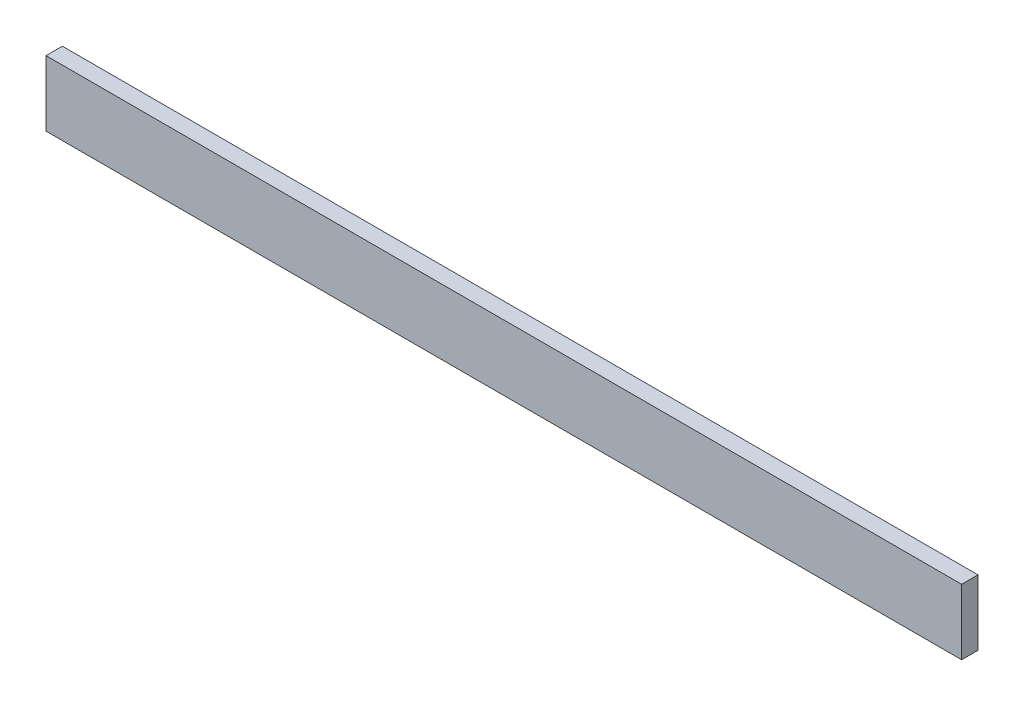
from build123d import *

# Parameters (mm, degrees)
SKETCH1_W           = 177.8
SKETCH1_H           = 12.7
BOSS_EXTRUDE1_DEPTH = 3.175


with BuildPart() as part:
    # Sketch1 → Boss-Extrude1 (new body)
    with BuildSketch(Plane.XY):
        Rectangle(SKETCH1_W, SKETCH1_H)
    extrude(amount=BOSS_EXTRUDE1_DEPTH)


solid = part.part
